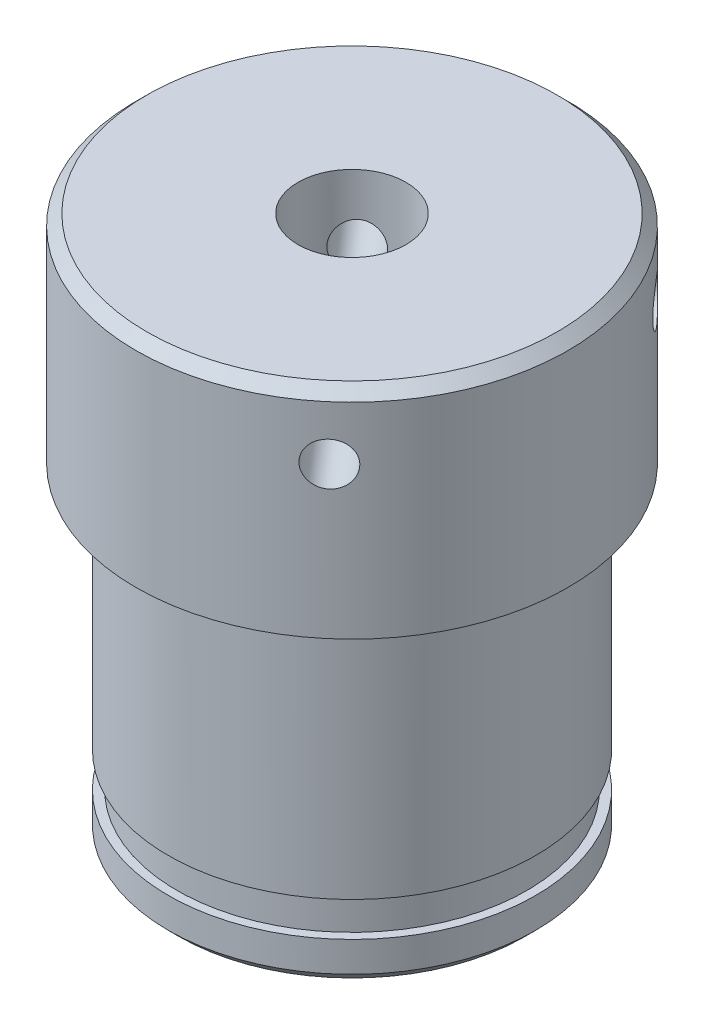
from build123d import *

# Parameters (mm, degrees)
SKETCH_1_R               = 8.5
EXTRUDE_1_DEPTH          = 15
SKETCH_2_R               = 10
EXTRUDE_2_DEPTH          = 10
SKETCH_3_R               = 1
CUT_EXTRUDE_1_DEPTH      = 10
CUT_EXTRUDE_START        = -1.9
SKETCH_4_R               = 8.5
SKETCH_4_R_2             = 8.1
CUT_EXTRUDE_2_DEPTH      = 1.6
CHAMFER_1_SIZE           = 0.5
SKETCH_7_R               = 1
CUT_EXTRUDE_3_DEPTH      = 8
PATTERN_CIRCULAR_1_COUNT = 4
SKETCH_8_R               = 3.5
CUT_EXTRUDE_4_DEPTH      = 5.5
CHAMFER_2_SIZE           = 0.5
CUT_EXTRUDE_5_REACH      = 21.5
SKETCH_9_R               = 2.5


with BuildPart() as part:
    # Эскиз1 → Бобышка-Вытянуть1 (new body)
    with BuildSketch(Plane(origin=(0, 0, 0), x_dir=(1, 0, 0), z_dir=(0, 1, 0))):
        Circle(SKETCH_1_R)
    extrude(amount=EXTRUDE_1_DEPTH)

    # Эскиз2 → Бобышка-Вытянуть2 (add)
    with BuildSketch(Plane(origin=(0, 15, 0), x_dir=(1, 0, 0), z_dir=(0, 1, 0))):
        Circle(SKETCH_2_R)
    extrude(amount=EXTRUDE_2_DEPTH)

    # Эскиз3 → Вырез-Вытянуть1 (cut)
    with BuildSketch(Plane.XZ):
        with Locations((0, 6)):
            Circle(SKETCH_3_R)
        with Locations((6, 0)):
            Circle(SKETCH_3_R)
        with Locations((0, -6)):
            Circle(SKETCH_3_R)
        with Locations((-6, 0)):
            Circle(SKETCH_3_R)
    extrude(amount=-CUT_EXTRUDE_1_DEPTH, mode=Mode.SUBTRACT)

    # Эскиз4 → Вырез-Вытянуть2 (cut)
    with BuildSketch(Plane.XZ.offset(CUT_EXTRUDE_START)):
        Circle(SKETCH_4_R)
        Circle(SKETCH_4_R_2, mode=Mode.SUBTRACT)
    extrude(amount=-CUT_EXTRUDE_2_DEPTH, mode=Mode.SUBTRACT)

    # Фаска1
    chamfer_1_edges = [part.edges().sort_by_distance(p)[0] for p in [
        (-8.5, 0, 0),
        (-10, 25, 0),
    ]]
    chamfer(chamfer_1_edges, length=CHAMFER_1_SIZE)

    # Эскиз7 → Вырез-Вытянуть3 (cut)
    with BuildSketch(Plane(origin=(6.524591557, 0, 7.578238913), x_dir=(0.757823891, 0, -0.652459156), z_dir=(0.652459156, 0, 0.757823891))):
        with Locations((0, 22)):
            Circle(SKETCH_7_R)
    cut_extrude_3 = extrude(amount=-CUT_EXTRUDE_3_DEPTH, mode=Mode.SUBTRACT)

    # Круговой массив1: Вырез-Вытянуть3 ×4 about axis
    pattern_circular_1_axis = Axis((0, 0, 0), (0, 1, 0))
    for i in range(1, PATTERN_CIRCULAR_1_COUNT):
        add(cut_extrude_3.rotate(pattern_circular_1_axis, i * 360 / PATTERN_CIRCULAR_1_COUNT), mode=Mode.SUBTRACT)

    # Эскиз8 → Вырез-Вытянуть4 (cut)
    with BuildSketch(Plane.XZ):
        Circle(SKETCH_8_R)
    extrude(amount=-CUT_EXTRUDE_4_DEPTH, mode=Mode.SUBTRACT)

    # Фаска2
    chamfer_2_edges = [part.edges().sort_by_distance(p)[0] for p in [
        (-3.5, 0, 0),
    ]]
    chamfer(chamfer_2_edges, length=CHAMFER_2_SIZE)

    # Эскиз9 → Вырез-Вытянуть5 (cut, up to next)
    with BuildSketch(Plane.XZ.offset(-5.5), mode=Mode.PRIVATE) as cut_extrude_5_sk1:
        Circle(SKETCH_9_R)
    cut_extrude_5_tool1 = extrude(cut_extrude_5_sk1.sketch, amount=-CUT_EXTRUDE_5_REACH, mode=Mode.PRIVATE) & part.part
    add(cut_extrude_5_tool1.solids().sort_by_distance((0, 5.5, 0))[0], mode=Mode.SUBTRACT)


solid = part.part
